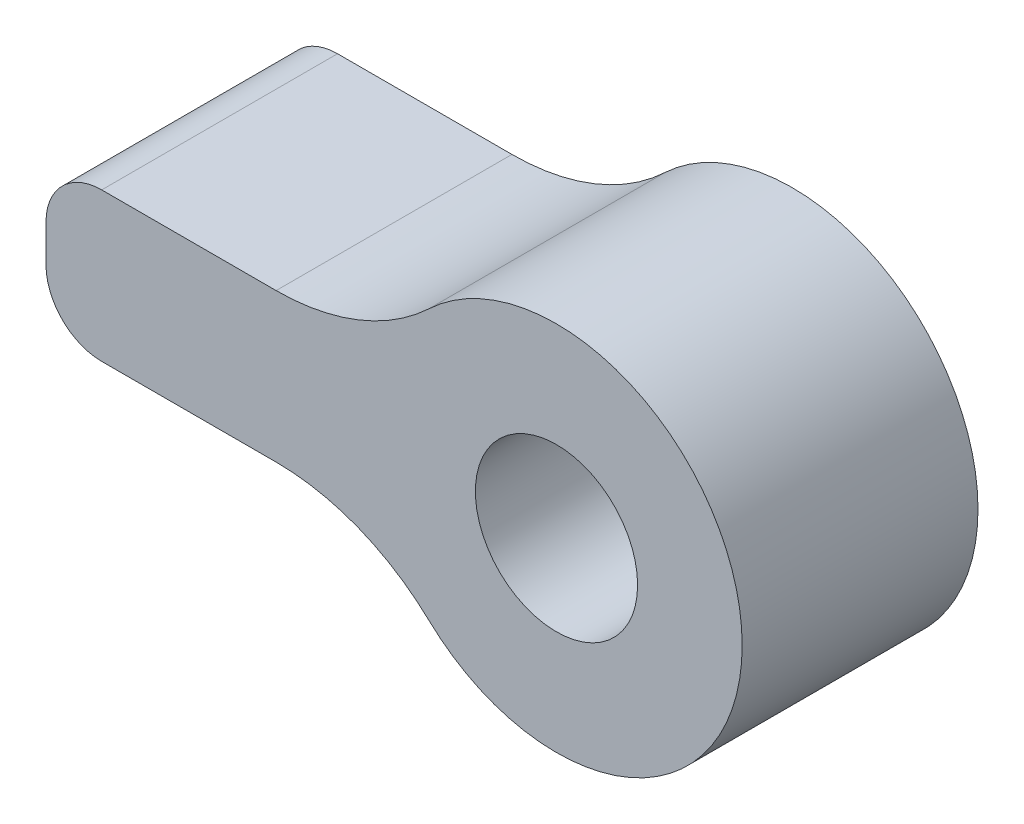
from build123d import *

# Parameters (mm, degrees)
SKETCH1_R           = 1.0922
BOSS_EXTRUDE1_DEPTH = 3.175


with BuildPart() as part:
    # Sketch1 → Boss-Extrude1 (new body)
    with BuildSketch(Plane.XY):
        with BuildLine():
            Line((97.519253807, 20.554833153), (97.617319935, 20.554833153))
            ThreePointArc((97.617319935, 20.554833153), (98.725143354, 20.766872021), (99.67636569, 21.373014971))
            ThreePointArc((99.67636569, 21.373014971), (103.892237153, 19.554833153), (99.67636569, 17.736651335))
            ThreePointArc((99.67636569, 17.736651335), (98.725143354, 18.342794285), (97.617319935, 18.554833153))
            Line((97.617319935, 18.554833153), (97.519253807, 18.554833153))
            Line((97.519253807, 18.554833153), (95.269253807, 18.554833153))
            ThreePointArc((95.269253807, 18.554833153), (94.738923721, 18.774503067), (94.519253807, 19.304833153))
            Line((94.519253807, 19.304833153), (94.519253807, 19.804833153))
            ThreePointArc((94.519253807, 19.804833153), (94.738923721, 20.335163239), (95.269253807, 20.554833153))
            Line((95.269253807, 20.554833153), (97.519253807, 20.554833153))
        make_face()
        with Locations((101.392237153, 19.554833153)):
            Circle(SKETCH1_R, mode=Mode.SUBTRACT)
    extrude(amount=BOSS_EXTRUDE1_DEPTH)


solid = part.part
